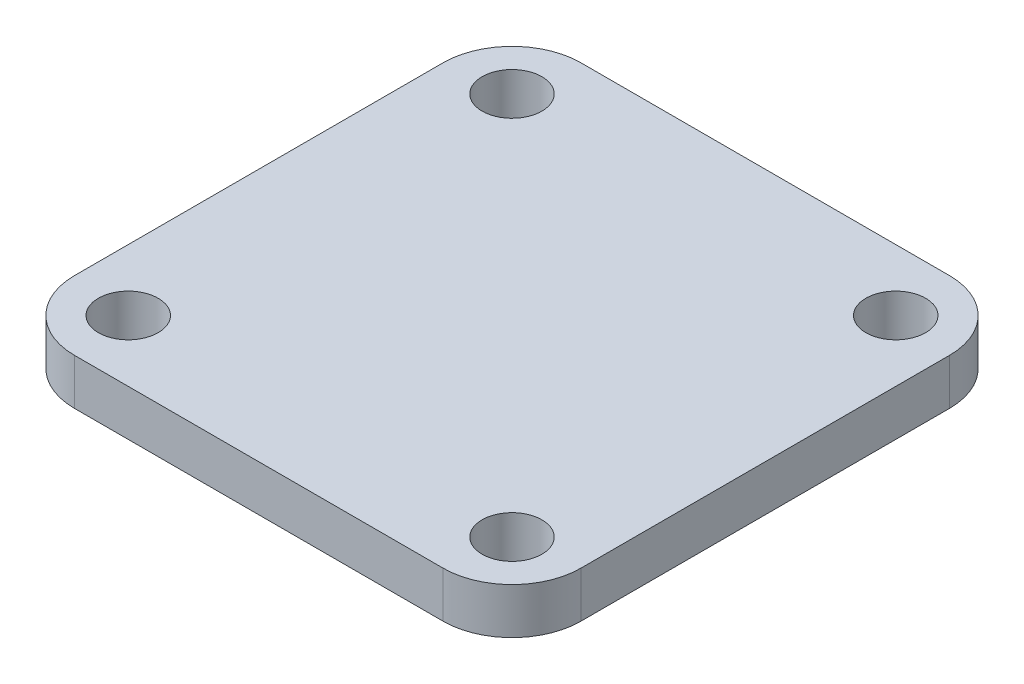
from build123d import *

# Parameters (mm, degrees)
SKETCH1_W           = 55.1
SKETCH1_H           = 55.1
SKETCH1_R           = 3.25
BOSS_EXTRUDE1_DEPTH = 5
FILLET1_R           = 7.5


with BuildPart() as part:
    # Sketch1 → Boss-Extrude1 (new body)
    with BuildSketch(Plane(origin=(0, 0, 0), x_dir=(1, 0, 0), z_dir=(0, 1, 0))):
        Rectangle(SKETCH1_W, SKETCH1_H)
        with Locations((20.87, -20.87)):
            Circle(SKETCH1_R, mode=Mode.SUBTRACT)
        with Locations((-20.87, -20.87)):
            Circle(SKETCH1_R, mode=Mode.SUBTRACT)
        with Locations((-20.87, 20.87)):
            Circle(SKETCH1_R, mode=Mode.SUBTRACT)
        with Locations((20.87, 20.87)):
            Circle(SKETCH1_R, mode=Mode.SUBTRACT)
    extrude(amount=BOSS_EXTRUDE1_DEPTH)

    # Fillet1
    fillet1_edges = [part.edges().sort_by_distance(p)[0] for p in [
        (27.55, 2.5, 27.55),
        (-27.55, 2.5, 27.55),
        (-27.55, 2.5, -27.55),
        (27.55, 2.5, -27.55),
    ]]
    fillet(fillet1_edges, radius=FILLET1_R)


solid = part.part
